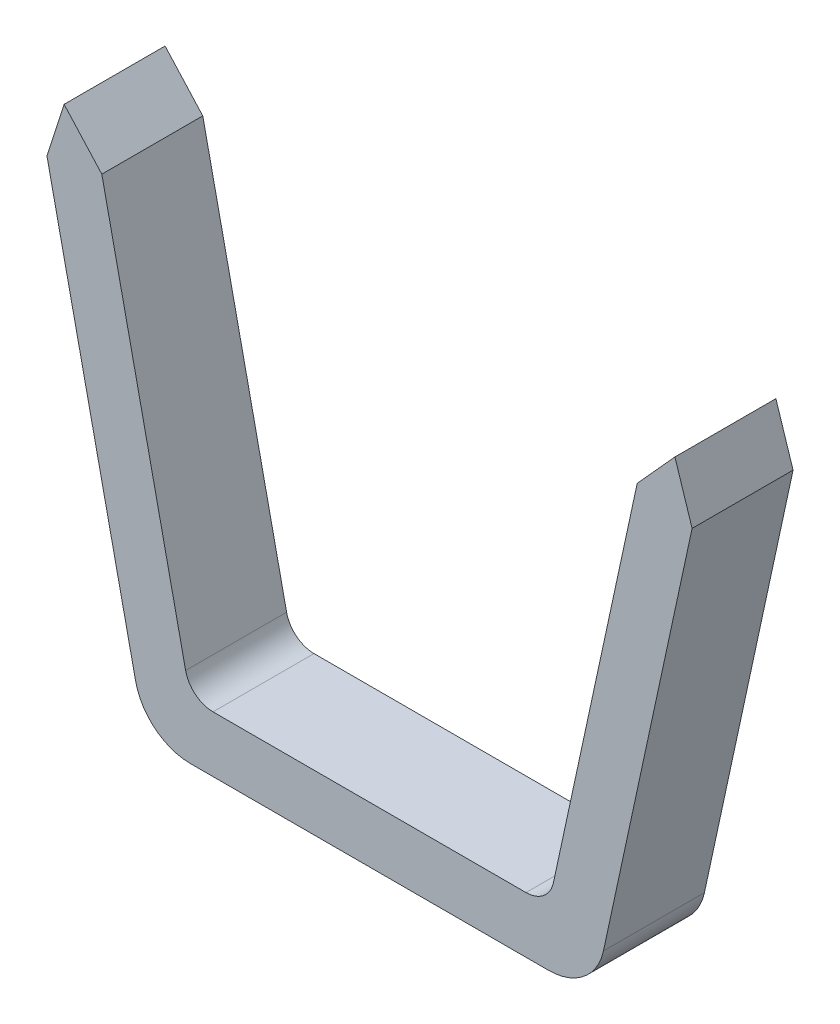
from build123d import *

# Parameters (mm, degrees)
SKETCH3_R           = 4.5
BOSS_EXTRUDE1_DEPTH = 18
FILLET1_R           = 5
FILLET2_R           = 5
CUT_EXTRUDE2_DEPTH  = 19.0000001


with BuildPart() as part:
    # Sketch3 → Boss-Extrude1 (new body)
    with BuildSketch(Plane.XY):
        with BuildLine():
            Line((-31.929873349, -122.5), (31.929873349, -122.5))
            ThreePointArc((31.929873349, -122.5), (38.210043039, -120.281996444), (41.704324989, -114.611893732))
            Line((41.704324989, -114.611893732), (73.308387301, 31.660797012))
            ThreePointArc((73.308387301, 31.660797012), (0, 122.5), (-73.308387301, 31.660797012))
            Line((-73.308387301, 31.660797012), (-41.704324989, -114.611893732))
            ThreePointArc((-41.704324989, -114.611893732), (-38.210043039, -120.281996444), (-31.929873349, -122.5))
        make_face()
        with Locations((50, -12.5)):
            Circle(SKETCH3_R, mode=Mode.SUBTRACT)
        with Locations((50, 87.5)):
            Circle(SKETCH3_R, mode=Mode.SUBTRACT)
        with Locations((-50, 87.5)):
            Circle(SKETCH3_R, mode=Mode.SUBTRACT)
        with Locations((-50, -12.5)):
            Circle(SKETCH3_R, mode=Mode.SUBTRACT)
        with BuildLine():
            Line((-31.929873349, -112.5), (-51.284518999, -22.921132901))
            ThreePointArc((-51.284518999, -22.921132901), (-39.736825778, -10.282511582), (-55.472323677, -3.538768301))
            Line((-55.472323677, -3.538768301), (-63.533935661, 33.772690744))
            ThreePointArc((-63.533935661, 33.772690744), (-64.271528905, 57.204152316), (-56.648842383, 79.373322021))
            ThreePointArc((-56.648842383, 79.373322021), (-41.800877501, 80.940702001), (-43.531035666, 95.770580418))
            ThreePointArc((-43.531035666, 95.770580418), (0, 112.5), (43.531035666, 95.770580418))
            ThreePointArc((43.531035666, 95.770580418), (41.800877501, 80.940702001), (56.648842383, 79.373322021))
            ThreePointArc((56.648842383, 79.373322021), (64.271528905, 57.204152316), (63.533935661, 33.772690744))
            Line((63.533935661, 33.772690744), (55.472323677, -3.538768301))
            ThreePointArc((55.472323677, -3.538768301), (39.736825778, -10.282511582), (51.284518999, -22.921132901))
            Line((51.284518999, -22.921132901), (31.929873349, -112.5))
            Line((31.929873349, -112.5), (-31.929873349, -112.5))
        make_face(mode=Mode.SUBTRACT)
    extrude(amount=BOSS_EXTRUDE1_DEPTH)

    # Fillet1
    fillet1_edges = [part.edges().sort_by_distance(p)[0] for p in [
        (-31.929873349, -112.5, 9),
        (31.929873349, -112.5, 9),
    ]]
    fillet(fillet1_edges, radius=FILLET1_R)

    # Fillet2
    fillet2_edges = [part.edges().sort_by_distance(p)[0] for p in [
        (51.284518999, -22.921132901, 9),
        (55.472323677, -3.538768301, 9),
        (56.648842383, 79.373322021, 9),
        (43.531035666, 95.770580418, 9),
        (-43.531035666, 95.770580418, 9),
        (-56.648842383, 79.373322021, 9),
        (-55.472323677, -3.538768301, 9),
        (-51.284518999, -22.921132901, 9),
    ]]
    fillet(fillet2_edges, radius=FILLET2_R)

    # Sketch5 → Cut-Extrude2 (cut, through all)
    with BuildSketch(Plane.XY.offset(18)):
        Polygon((47.724403212, -39.39837277), (54.444339069, -31.972010438), (57.506356145, -41.47554836), (172.58444794, 157.130363262), (-148.336678287, 157.130363262), (-57.506356145, -41.47554836), (-54.443982463, -31.973660914), (-47.723687693, -39.401684395), align=None)
    extrude(amount=-CUT_EXTRUDE2_DEPTH, mode=Mode.SUBTRACT)


solid = part.part
